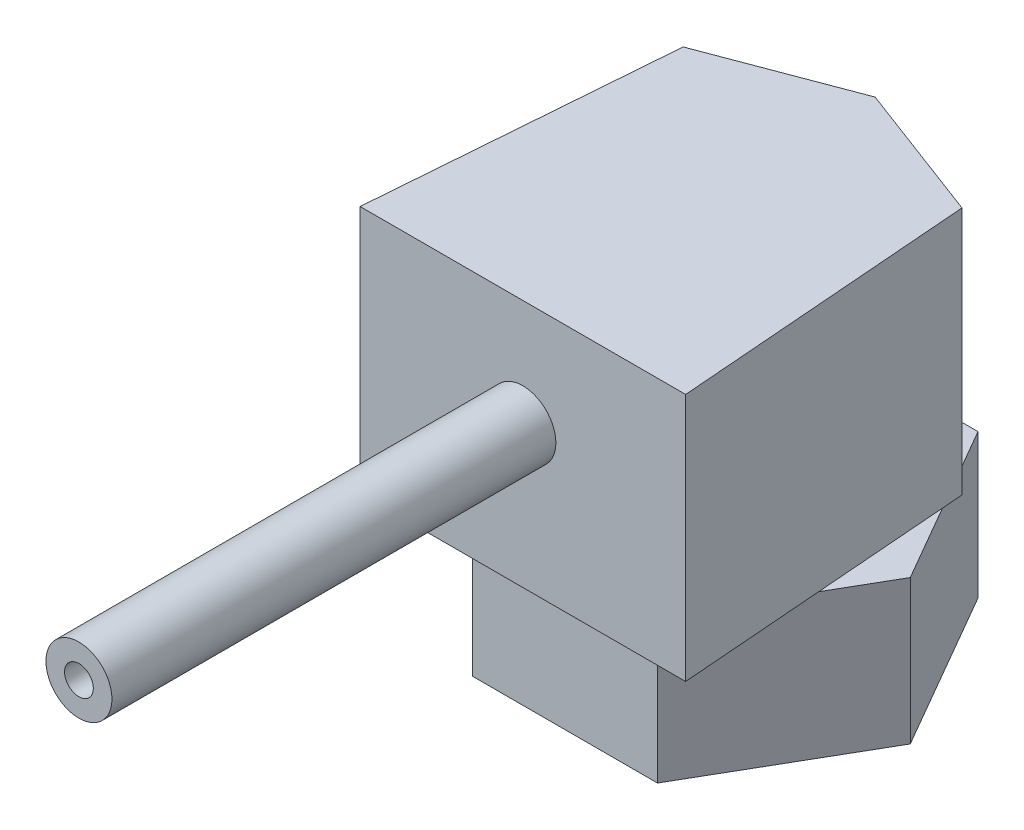
from build123d import *

# Parameters (mm, degrees)
BOSS_EXTRUDE1_DEPTH = 4.87
BOSS_EXTRUDE2_DEPTH = 8.4
SKETCH3_R           = 1.115
SKETCH3_R_2         = 0.48582374
BOSS_EXTRUDE3_DEPTH = 15
SKETCH4_R           = 2.886437974
BOSS_EXTRUDE4_DEPTH = 0.5


with BuildPart() as part:
    # Sketch1 → Boss-Extrude1 (new body)
    with BuildSketch(Plane(origin=(0, 0, 0), x_dir=(1, 0, 0), z_dir=(0, 1, 0))):
        Polygon((6.252703415, 0), (3.126351708, 5.415), (-3.126351708, 5.415), (-6.252703415, 0), (-3.126351708, -5.415), (3.126351708, -5.415), align=None)
    extrude(amount=BOSS_EXTRUDE1_DEPTH)

    # Sketch2 → Boss-Extrude2 (add)
    with BuildSketch(Plane(origin=(0, 4.87, 0), x_dir=(1, 0, 0), z_dir=(0, 1, 0))):
        Polygon((0, 5.065814818), (-4.710329867, 3.289588054), (-5.5, -6.837347299), (-1.528536321, -6.837347299), (5.5, -6.837347299), (4.710329867, 3.289588054), align=None)
    extrude(amount=BOSS_EXTRUDE2_DEPTH)

    # Sketch3 → Boss-Extrude3 (add)
    with BuildSketch(Plane.XY.offset(6.837347299)):
        with Locations((0, 9.66)):
            Circle(SKETCH3_R)
        with Locations((0, 9.66)):
            Circle(SKETCH3_R_2, mode=Mode.SUBTRACT)
    extrude(amount=BOSS_EXTRUDE3_DEPTH)

    # Sketch4 → Boss-Extrude4 (add)
    with BuildSketch(Plane.XZ):
        Circle(SKETCH4_R)
    extrude(amount=BOSS_EXTRUDE4_DEPTH)


solid = part.part
